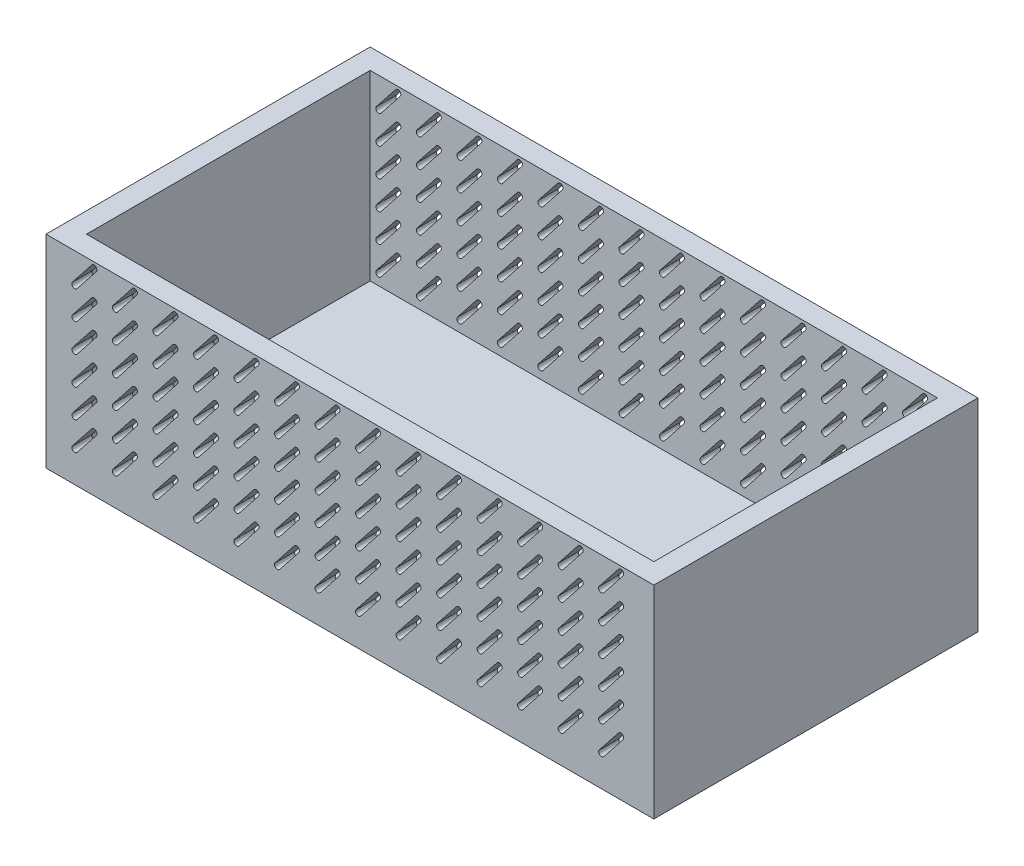
from build123d import *

# Parameters (mm, degrees)
ESQUISSE2_W                     = 300
ESQUISSE2_H                     = 160
BOSS_EXTRU_1_DEPTH              = 100
COQUE2_T                        = -10
ENL_V_MAT_EXTRU_1_DEPTH         = 170
R_P_TITION_LIN_AIRE3_COUNT      = 6
R_P_TITION_LIN_AIRE3_PITCH      = 14
R_P_TITION_LIN_AIRE3_COUNT_DIR2 = 14
R_P_TITION_LIN_AIRE3_PITCH_DIR2 = 20


with BuildPart() as part:
    # Esquisse2 → Boss.-Extru.1 (new body)
    with BuildSketch(Plane(origin=(0, 0, 0), x_dir=(1, 0, 0), z_dir=(0, 1, 0))):
        Rectangle(ESQUISSE2_W, ESQUISSE2_H)
    extrude(amount=-BOSS_EXTRU_1_DEPTH)

    # Coque2
    coque2_openings = [part.faces().sort_by_distance(p)[0] for p in [
        (0, 0, 0),
    ]]
    offset(amount=COQUE2_T, openings=coque2_openings, kind=Kind.INTERSECTION)

    # Esquisse5 → Enlèv. mat.-Extru.1 (cut, symmetric)
    with BuildSketch(Plane.XY.offset(-70)):
        with BuildLine():
            Line((-136.943396754, -13.938664257), (-127.409910618, -1.904591593))
            ThreePointArc((-127.409910618, -1.904591593), (-125.416308291, -1.673449294), (-125.185165992, -3.66705162))
            Line((-125.185165992, -3.66705162), (-134.718652129, -15.701124285))
            ThreePointArc((-134.718652129, -15.701124285), (-136.712254456, -15.932266584), (-136.943396754, -13.938664257))
        make_face()
    enl_v_mat_extru_1 = extrude(amount=ENL_V_MAT_EXTRU_1_DEPTH, both=True, mode=Mode.SUBTRACT)

    # Répétition linéaire3: Enl_v. mat.-Extru.1 6 × 14
    with Locations(*[(j * R_P_TITION_LIN_AIRE3_PITCH_DIR2, -i * R_P_TITION_LIN_AIRE3_PITCH, 0) for i in range(R_P_TITION_LIN_AIRE3_COUNT) for j in range(R_P_TITION_LIN_AIRE3_COUNT_DIR2) if (i, j) != (0, 0)]):
        add(enl_v_mat_extru_1, mode=Mode.SUBTRACT)


solid = part.part
